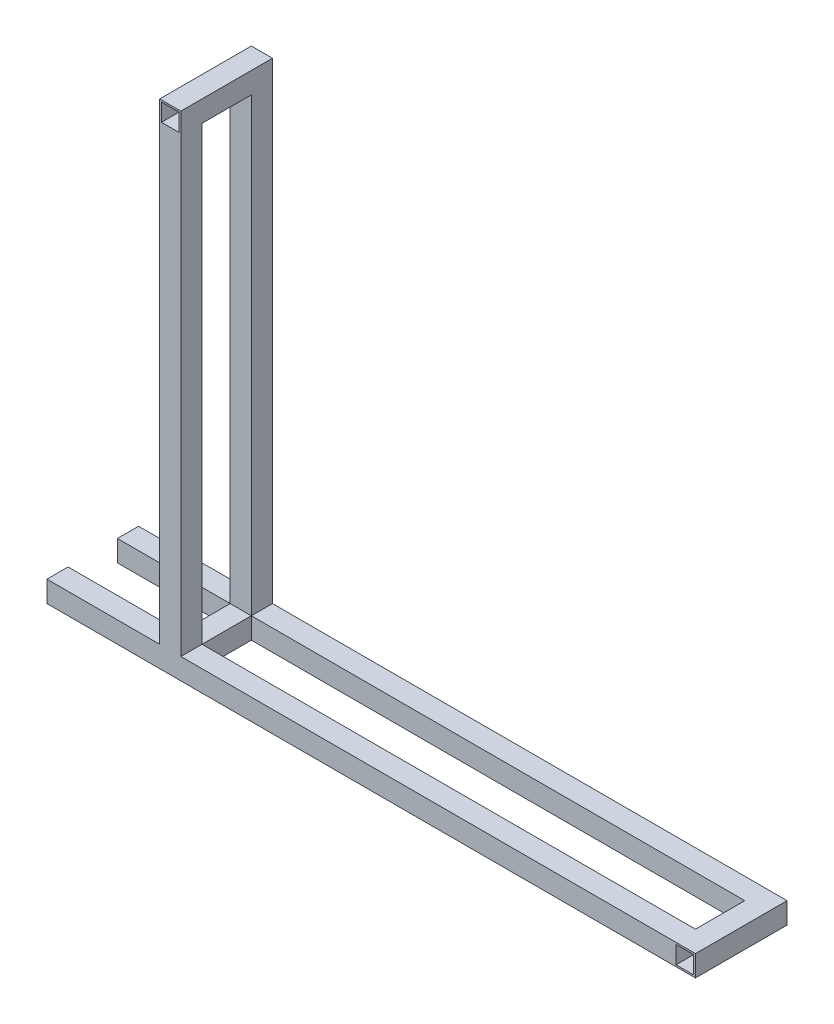
from build123d import *

# Parameters (mm, degrees)
SALIENTE_EXTRUIR1_DEPTH = 9.525
SALIENTE_EXTRUIR2_DEPTH = 19.05
SALIENTE_EXTRUIR6_START = -82.55
CROQUIS9_W              = 19.05
CROQUIS9_H              = 19.05
CROQUIS9_W_2            = 15.875
CROQUIS9_H_2            = 15.875
SALIENTE_EXTRUIR6_DEPTH = 82.55
CROQUIS10_W             = 19.05
CROQUIS10_H             = 19.05
SALIENTE_EXTRUIR7_DEPTH = 44.45
CROQUIS11_W             = 19.05
CROQUIS11_H             = 19.05
SALIENTE_EXTRUIR8_DEPTH = 101.6
CROQUIS12_W             = 15.875
CROQUIS12_H             = 15.875
CORTAR_EXTRUIR2_DEPTH   = 565.15


with BuildPart() as part:
    # Croquis2 → Saliente-Extruir1 (new body, symmetric)
    with BuildSketch(Plane.XY):
        Polygon((-19.05, -19.05), (-19.05, 406.4), (0, 406.4), (0, 0), (444.5, 0), (444.5, -19.05), align=None)
    extrude(amount=SALIENTE_EXTRUIR1_DEPTH, both=True)



with BuildPart() as body_2:
    # Croquis3 → Saliente-Extruir2 (new body)
    with BuildSketch(Plane.XY.offset(53.975)):
        Polygon((-19.05, -19.05), (-19.05, 406.4), (0, 406.4), (0, 0), (444.5, 0), (444.5, -19.05), align=None)
    extrude(amount=SALIENTE_EXTRUIR2_DEPTH)


with BuildPart() as part_1:
    add(part.part)

    add(body_2.part)  # Saliente-Extruir6 merges body 2
    # Croquis9 → Saliente-Extruir6 (add)
    with BuildSketch(Plane.XY.offset(73.025).offset(SALIENTE_EXTRUIR6_START)):
        with Locations((-9.525, 415.925)):
            Rectangle(CROQUIS9_W, CROQUIS9_H)
        with Locations((-9.525, 415.925)):
            Rectangle(CROQUIS9_W_2, CROQUIS9_H_2, mode=Mode.SUBTRACT)
        with Locations((454.025, -9.525)):
            Rectangle(CROQUIS9_W, CROQUIS9_H)
        with Locations((454.025, -9.525)):
            Rectangle(CROQUIS9_W_2, CROQUIS9_H_2, mode=Mode.SUBTRACT)
    extrude(amount=SALIENTE_EXTRUIR6_DEPTH)

    # Croquis10 → Saliente-Extruir7 (add)
    with BuildSketch(Plane.XY.offset(9.525)):
        with Locations((-9.525, -9.525)):
            Rectangle(CROQUIS10_W, CROQUIS10_H)
    extrude(amount=SALIENTE_EXTRUIR7_DEPTH)

    # Croquis11 → Saliente-Extruir8 (add)
    with BuildSketch(Plane.ZY.offset(19.05)):
        with Locations((0, -9.525)):
            Rectangle(CROQUIS11_W, CROQUIS11_H)
        with Locations((63.5, -9.525)):
            Rectangle(CROQUIS11_W, CROQUIS11_H)
    extrude(amount=SALIENTE_EXTRUIR8_DEPTH)

    # Croquis12 → Cortar-Extruir2 (cut)
    with BuildSketch(Plane.ZY.offset(120.65)):
        with Locations((0, -9.525)):
            Rectangle(CROQUIS12_W, CROQUIS12_H)
        with Locations((63.5, -9.525)):
            Rectangle(CROQUIS12_W, CROQUIS12_H)
    extrude(amount=-CORTAR_EXTRUIR2_DEPTH, mode=Mode.SUBTRACT)


solid = part_1.part
